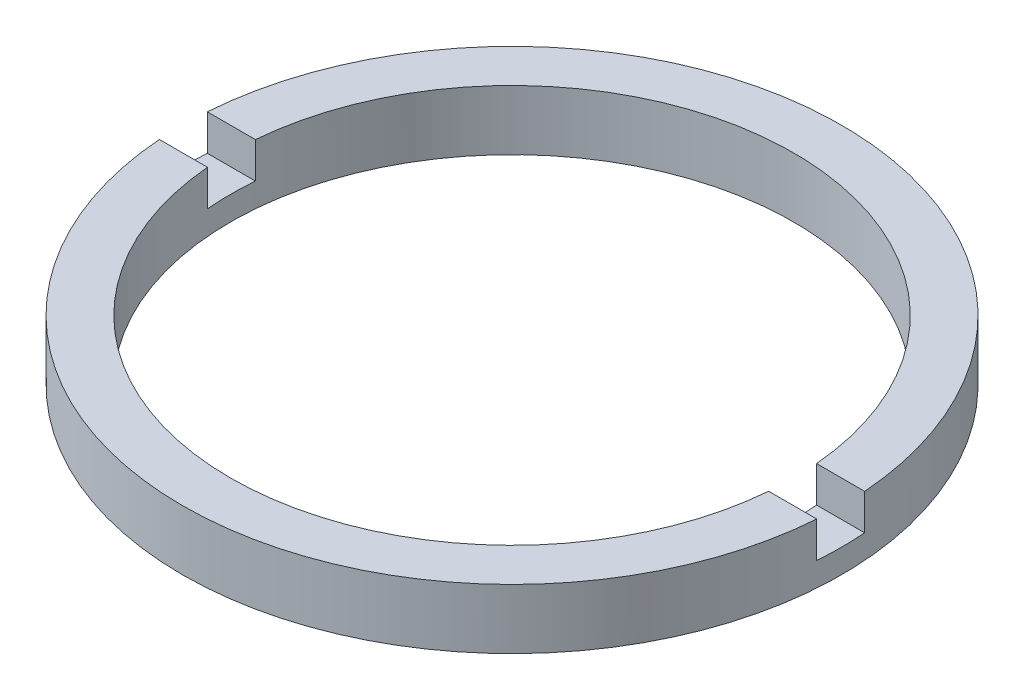
from build123d import *

# Parameters (mm, degrees)
SKETCH_1_W          = 2
SKETCH_1_H          = 2.5
SKETCH_2_W          = 53.705080546
SKETCH_2_H          = 2
CUT_EXTRUDE_1_DEPTH = 1.5


with BuildPart() as part:
    # 草图1 → 旋转1 (revolve)
    with BuildSketch(Plane.XY, mode=Mode.PRIVATE) as revolve_1_sk:
        with Locations((12.75, -3.214249787)):
            Rectangle(SKETCH_1_W, SKETCH_1_H)
    revolve(revolve_1_sk.sketch.rotate(Axis((0, 56.260842627, 0), (0, -1, 0)), 90), axis=Axis((0, 56.260842627, 0), (0, -1, 0)))  # turned: the seam where the file's is

    # 草图2 → 切除-拉伸1 (cut)
    with BuildSketch(Plane(origin=(0, -1.964249787, 0), x_dir=(1, 0, 0), z_dir=(0, 1, 0))):
        Rectangle(SKETCH_2_W, SKETCH_2_H)
    extrude(amount=-CUT_EXTRUDE_1_DEPTH, mode=Mode.SUBTRACT)


solid = part.part
